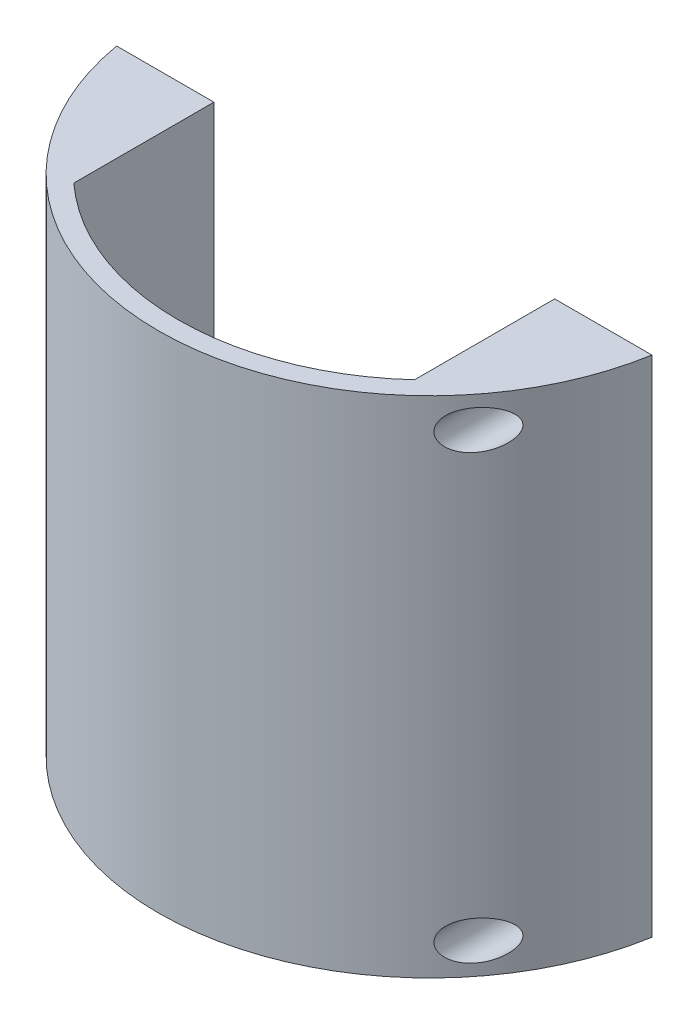
from build123d import *

# Parameters (mm, degrees)
BOSS_EXTRUDE1_DEPTH   = 82.55
BOSS_EXTRUDE2_REACH   = 38.963
SKETCH4_W             = 12.7
SKETCH4_H             = 82.55
F_6_CLEARANCE_HOLE1_D = 3.7973
SKETCH7_R             = 3.175
CUT_EXTRUDE1_DEPTH    = 31.613460512


with BuildPart() as part:
    # Sketch3 → Boss-Extrude1 (new body)
    with BuildSketch(Plane(origin=(0, 0, 0), x_dir=(1, 0, 0), z_dir=(0, 1, 0))):
        with BuildLine():
            Line((-43.815, -7.486539588), (-40.590360309, -7.486539588))
            ThreePointArc((-40.590360309, -7.486539588), (0, -41.275), (40.590360309, -7.486539588))
            Line((40.590360309, -7.486539588), (43.815, -7.486539588))
            ThreePointArc((43.815, -7.486539588), (0, -44.45), (-43.815, -7.486539588))
        make_face()
    extrude(amount=BOSS_EXTRUDE1_DEPTH)

    # Sketch4 → Boss-Extrude2 (add, up to next)
    with BuildSketch(Plane(origin=(0, 0, 7.486539588), x_dir=(-1, 0, 0), z_dir=(0, 0, -1)), mode=Mode.PRIVATE) as boss_extrude2_sk1:
        with Locations((-34.240360309, 41.275)):
            Rectangle(SKETCH4_W, SKETCH4_H)
    boss_extrude2_tool1 = extrude(boss_extrude2_sk1.sketch, amount=-BOSS_EXTRUDE2_REACH, mode=Mode.PRIVATE) - part.part
    add(boss_extrude2_tool1.solids().sort_by_distance((34.24036, 41.275, 7.48654))[0])
    # Sketch4 → Boss-Extrude2 (add, up to next)
    with BuildSketch(Plane(origin=(0, 0, 7.486539588), x_dir=(-1, 0, 0), z_dir=(0, 0, -1)), mode=Mode.PRIVATE) as boss_extrude2_sk2:
        with Locations((34.240360309, 41.275)):
            Rectangle(SKETCH4_W, SKETCH4_H)
    boss_extrude2_tool2 = extrude(boss_extrude2_sk2.sketch, amount=-BOSS_EXTRUDE2_REACH, mode=Mode.PRIVATE) - part.part
    add(boss_extrude2_tool2.solids().sort_by_distance((-34.24036, 41.275, 7.48654))[0])

    # #6 Clearance Hole1 (through all)
    with Locations(Plane(origin=(0, 0, 7.486539588), x_dir=(-1, 0, 0), z_dir=(0, 0, -1))):
        with Locations((-34.925, 77.47), (-34.925, 5.08), (34.925, 77.47), (34.925, 5.08)):
            Hole(F_6_CLEARANCE_HOLE1_D / 2)

    # Sketch7 → Cut-Extrude1 (cut, through all)
    with BuildSketch(Plane(origin=(0, 0, 13.836539588), x_dir=(-1, 0, 0), z_dir=(0, 0, -1))):
        with Locations((-34.925, 5.08)):
            Circle(SKETCH7_R)
        with Locations((34.925, 5.08)):
            Circle(SKETCH7_R)
        with Locations((34.925, 77.47)):
            Circle(SKETCH7_R)
        with Locations((-34.925, 77.47)):
            Circle(SKETCH7_R)
    extrude(amount=-CUT_EXTRUDE1_DEPTH, mode=Mode.SUBTRACT)


solid = part.part
